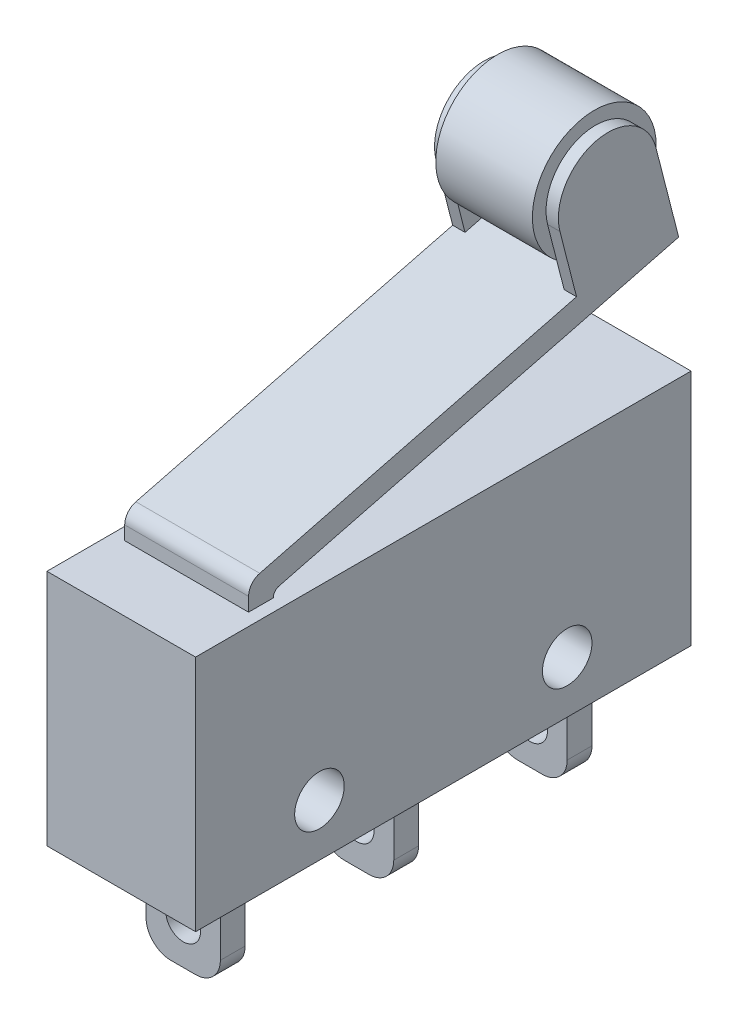
from build123d import *

# Parameters (mm, degrees)
SKETCH1_W           = 20
SKETCH1_H           = 9.6
SKETCH1_W_2         = 1
SKETCH1_H_2         = 4
BOSS_EXTRUDE1_DEPTH = 3
SKETCH2_R           = 1
CUT_EXTRUDE1_DEPTH  = 6
SKETCH4_W           = 1.5
SKETCH4_H           = 4
CUT_EXTRUDE2_DEPTH  = 18.5
CUT_EXTRUDE3_DEPTH  = 0.5
SKETCH6_W           = 4
SKETCH6_H           = 4.7
CUT_EXTRUDE4_DEPTH  = 6.262080904
SKETCH7_R           = 2.5
BOSS_EXTRUDE2_DEPTH = 1.95
FILLET1_R           = 1


with BuildPart() as part:
    # Sketch1 → Boss-Extrude1 (new body, symmetric)
    with BuildSketch(Plane(origin=(0, 0, 0), x_dir=(0, 0, -1), z_dir=(1, 0, 0))):
        Rectangle(SKETCH1_W, SKETCH1_H)
        with BuildLine():
            Line((5.207264869, 11.823485535), (5.876960726, 9.20785799))
            Line((5.876960726, 9.20785799), (9.751964497, 10.2))
            Line((9.751964497, 10.2), (9.08226864, 12.815627546))
            ThreePointArc((9.08226864, 12.815627546), (6.648695749, 14.257058427), (5.207264869, 11.823485535))
        make_face()
        with BuildLine():
            Line((5.876960726, 9.20785799), (-6.909917136, 5.933951832))
            ThreePointArc((-6.909917136, 5.933951832), (-7.2350646, 5.720605614), (-7.361095835, 5.352701266))
            Line((-7.361095835, 5.352701266), (-7.361095835, 4.8))
            Line((-7.361095835, 4.8), (-6.361095835, 4.8))
            Line((-6.361095835, 4.8), (-6.361095835, 4.809346803))
            ThreePointArc((-6.361095835, 4.809346803), (-6.298080217, 4.993298978), (-6.135506485, 5.099972086))
            Line((-6.135506485, 5.099972086), (10, 9.231249057))
            Line((10, 9.231249057), (9.751964497, 10.2))
            Line((9.751964497, 10.2), (5.876960726, 9.20785799))
        make_face()
        with BuildLine():
            Line((5.207264869, 11.823485535), (5.876960726, 9.20785799))
            Line((5.876960726, 9.20785799), (9.751964497, 10.2))
            Line((9.751964497, 10.2), (9.08226864, 12.815627546))
            ThreePointArc((9.08226864, 12.815627546), (6.648695749, 14.257058427), (5.207264869, 11.823485535))
        make_face()
        with Locations((-7, -6.8)):
            Rectangle(SKETCH1_W_2, SKETCH1_H_2)
        with Locations((0, -6.8)):
            Rectangle(SKETCH1_W_2, SKETCH1_H_2)
        with Locations((7, -6.8)):
            Rectangle(SKETCH1_W_2, SKETCH1_H_2)
    extrude(amount=BOSS_EXTRUDE1_DEPTH, both=True)

    # Sketch2 → Cut-Extrude1 (cut)
    with BuildSketch(Plane(origin=(3, 0, 0), x_dir=(0, 0, -1), z_dir=(1, 0, 0))):
        with Locations((-5, -2.7)):
            Circle(SKETCH2_R)
        with Locations((5, -2.7)):
            Circle(SKETCH2_R)
    extrude(amount=-CUT_EXTRUDE1_DEPTH, mode=Mode.SUBTRACT)

    # Sketch4 → Cut-Extrude2 (cut, through all)
    with BuildSketch(Plane.XY.offset(7.5)):
        with Locations((2.25, -6.8)):
            Rectangle(SKETCH4_W, SKETCH4_H)
        with Locations((-2.25, -6.8)):
            Rectangle(SKETCH4_W, SKETCH4_H)
        with BuildLine():
            Line((-0.7, -7.2), (-0.7, -6.4))
            ThreePointArc((-0.7, -6.4), (0, -5.7), (0.7, -6.4))
            Line((0.7, -6.4), (0.7, -7.2))
            ThreePointArc((0.7, -7.2), (0, -7.9), (-0.7, -7.2))
        make_face()
    extrude(amount=-CUT_EXTRUDE2_DEPTH, mode=Mode.SUBTRACT)

    # Sketch5 → Cut-Extrude3 (cut)
    with BuildSketch(Plane(origin=(3, 0, 0), x_dir=(0, 0, -1), z_dir=(1, 0, 0))):
        with BuildLine():
            Line((-6.361095835, 4.8), (-7.361095835, 4.8))
            Line((-7.361095835, 4.8), (-7.361095835, 5.352701266))
            ThreePointArc((-7.361095835, 5.352701266), (-7.2350646, 5.720605614), (-6.909917136, 5.933951832))
            Line((-6.909917136, 5.933951832), (5.876960726, 9.20785799))
            Line((5.876960726, 9.20785799), (5.207264869, 11.823485535))
            ThreePointArc((5.207264869, 11.823485535), (6.648695749, 14.257058427), (9.08226864, 12.815627546))
            Line((9.08226864, 12.815627546), (10, 9.231249057))
            Line((10, 9.231249057), (-6.135506485, 5.099972086))
            ThreePointArc((-6.135506485, 5.099972086), (-6.298080217, 4.993298978), (-6.361095835, 4.809346803))
            Line((-6.361095835, 4.809346803), (-6.361095835, 4.8))
        make_face()
    cut_extrude3 = extrude(amount=-CUT_EXTRUDE3_DEPTH, mode=Mode.SUBTRACT)

    # Mirror1: Cut-Extrude3 across plane
    add(cut_extrude3.mirror(Plane(origin=(0, 0, 0), x_dir=(0, 0, 1), z_dir=(1, 0, 0))), mode=Mode.SUBTRACT)

    # Sketch6 → Cut-Extrude4 (cut, through all)
    with BuildSketch(Plane(origin=(0, 1.978625569, -7.727907359), x_dir=(1, 0, 0), z_dir=(0, -0.248035503, 0.968750943))):
        with Locations((0, 9.812426202)):
            Rectangle(SKETCH6_W, SKETCH6_H)
    extrude(amount=-CUT_EXTRUDE4_DEPTH, mode=Mode.SUBTRACT)

    # Fillet1
    fillet1_edges = [part.edges().sort_by_distance(p)[0] for p in [
        (1.5, -8.8, -7),
        (1.5, -8.8, 0),
        (1.5, -8.8, 7),
        (-1.5, -8.8, -7),
        (-1.5, -8.8, 0),
        (-1.5, -8.8, 7),
    ]]
    fillet(fillet1_edges, radius=FILLET1_R)


with BuildPart() as body_2:
    # Sketch7 → Boss-Extrude2 (new body, symmetric)
    with BuildSketch(Plane(origin=(0, 0, 0), x_dir=(0, 0, -1), z_dir=(1, 0, 0))):
        with Locations((7.144766754, 12.319556541)):
            Circle(SKETCH7_R)
    extrude(amount=BOSS_EXTRUDE2_DEPTH, both=True)


solid = Compound([part.part, body_2.part])
